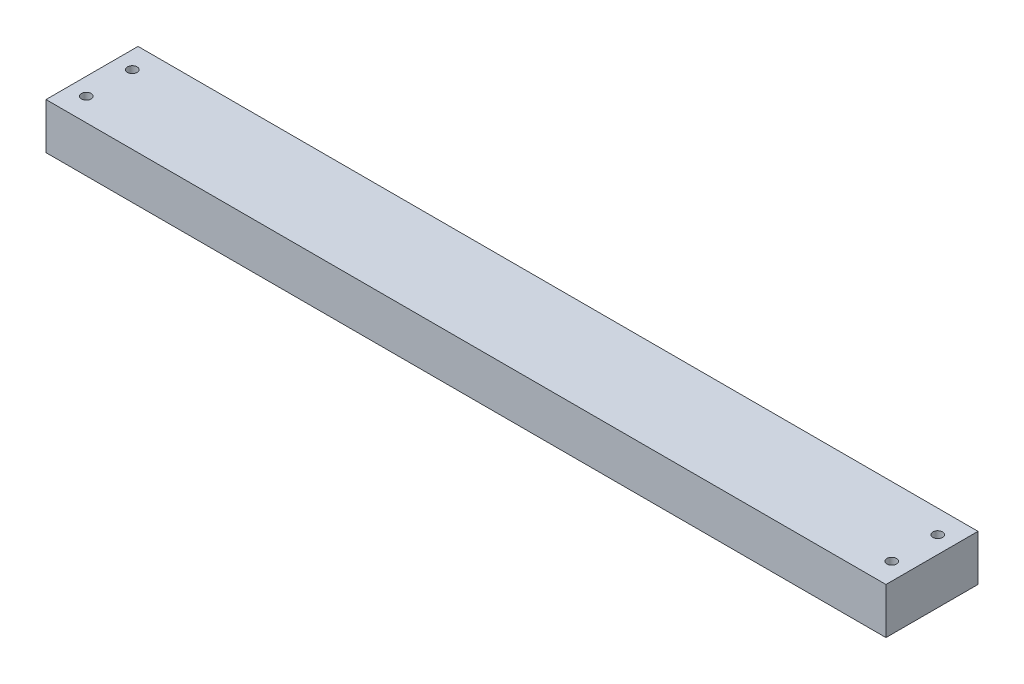
from build123d import *

# Parameters (mm, degrees)
SKETCH1_W           = 50.8
SKETCH1_H           = 25.4
BOSS_EXTRUDE1_DEPTH = 463.55
CUT_EXTRUDE1_REACH  = 27.4
SKETCH2_R           = 2.667


with BuildPart() as part:
    # Sketch1 → Boss-Extrude1 (new body)
    with BuildSketch(Plane(origin=(0, 0, 0), x_dir=(0, 0, -1), z_dir=(1, 0, 0))):
        Rectangle(SKETCH1_W, SKETCH1_H)
    extrude(amount=BOSS_EXTRUDE1_DEPTH)

    # Sketch2 → Cut-Extrude1 (cut, up to next)
    with BuildSketch(Plane(origin=(0, 12.7, 0), x_dir=(1, 0, 0), z_dir=(0, 1, 0)), mode=Mode.PRIVATE) as cut_extrude1_sk1:
        with Locations((9.525, 12.7)):
            Circle(SKETCH2_R)
    cut_extrude1_tool1 = extrude(cut_extrude1_sk1.sketch, amount=-CUT_EXTRUDE1_REACH, mode=Mode.PRIVATE) & part.part
    add(cut_extrude1_tool1.solids().sort_by_distance((9.525, 12.7, -12.7))[0], mode=Mode.SUBTRACT)
    # Sketch2 → Cut-Extrude1 (cut, up to next)
    with BuildSketch(Plane(origin=(0, 12.7, 0), x_dir=(1, 0, 0), z_dir=(0, 1, 0)), mode=Mode.PRIVATE) as cut_extrude1_sk2:
        with Locations((9.525, -12.7)):
            Circle(SKETCH2_R)
    cut_extrude1_tool2 = extrude(cut_extrude1_sk2.sketch, amount=-CUT_EXTRUDE1_REACH, mode=Mode.PRIVATE) & part.part
    add(cut_extrude1_tool2.solids().sort_by_distance((9.525, 12.7, 12.7))[0], mode=Mode.SUBTRACT)
    # Sketch2 → Cut-Extrude1 (cut, up to next)
    with BuildSketch(Plane(origin=(0, 12.7, 0), x_dir=(1, 0, 0), z_dir=(0, 1, 0)), mode=Mode.PRIVATE) as cut_extrude1_sk3:
        with Locations((454.025, -12.7)):
            Circle(SKETCH2_R)
    cut_extrude1_tool3 = extrude(cut_extrude1_sk3.sketch, amount=-CUT_EXTRUDE1_REACH, mode=Mode.PRIVATE) & part.part
    add(cut_extrude1_tool3.solids().sort_by_distance((454.025, 12.7, 12.7))[0], mode=Mode.SUBTRACT)
    # Sketch2 → Cut-Extrude1 (cut, up to next)
    with BuildSketch(Plane(origin=(0, 12.7, 0), x_dir=(1, 0, 0), z_dir=(0, 1, 0)), mode=Mode.PRIVATE) as cut_extrude1_sk4:
        with Locations((454.025, 12.7)):
            Circle(SKETCH2_R)
    cut_extrude1_tool4 = extrude(cut_extrude1_sk4.sketch, amount=-CUT_EXTRUDE1_REACH, mode=Mode.PRIVATE) & part.part
    add(cut_extrude1_tool4.solids().sort_by_distance((454.025, 12.7, -12.7))[0], mode=Mode.SUBTRACT)


solid = part.part
